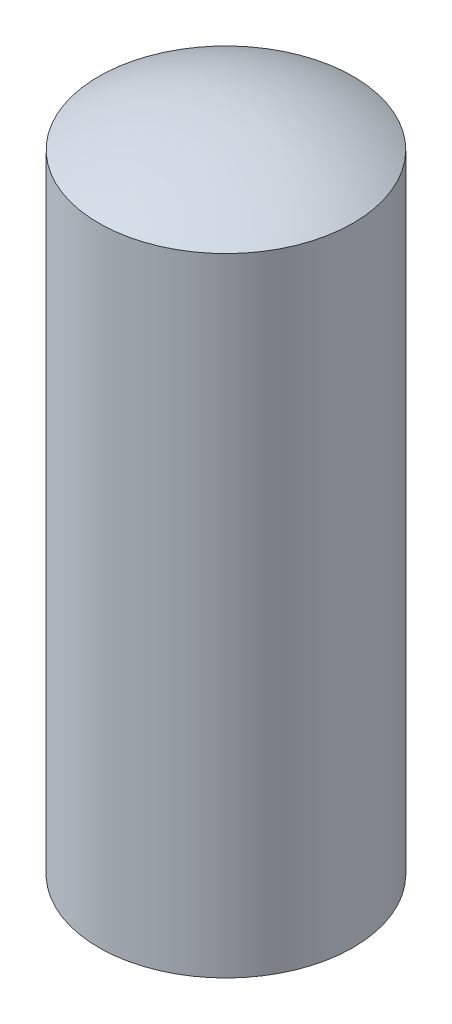
from build123d import *


with BuildPart() as part:
    # Esquisse1 → Révolution1 (revolve)
    with BuildSketch(Plane.XY):
        with BuildLine():
            Line((0, 0), (0, 3.9))
            ThreePointArc((0, 3.9), (0.388104367, 3.849141378), (0.75, 3.7))
            Line((0.75, 3.7), (0.75, 0))
            Line((0.75, 0), (0, 0))
        make_face()
    revolve(axis=Axis((0, 0, 0), (0, 1, 0)))


solid = part.part
